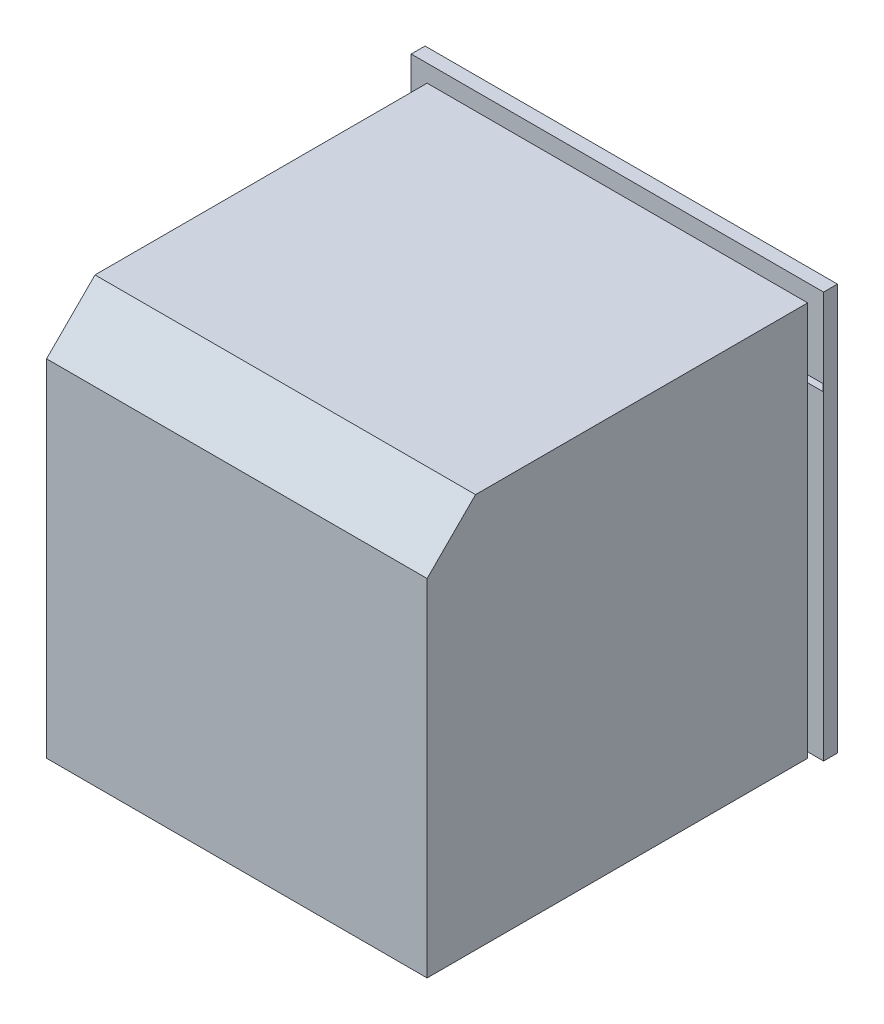
from build123d import *

# Parameters (mm, degrees)
SKETCH2_W           = 550
SKETCH2_H           = 570
BOSS_EXTRUDE2_DEPTH = 550
CHAMFER1_SIZE       = 70
SKETCH3_W           = 596
SKETCH3_H           = 595
BOSS_EXTRUDE3_DEPTH = 20
SKETCH4_W           = 595
SKETCH4_H           = 52
SKETCH4_W_2         = 596
SKETCH4_H_2         = 18
BOSS_EXTRUDE4_DEPTH = 0.01
SKETCH5_W           = 595
SKETCH5_H           = 8
SKETCH5_W_2         = 594
SKETCH5_H_2         = 10
CUT_EXTRUDE1_DEPTH  = 20.01
BOSS_EXTRUDE5_DEPTH = 30


with BuildPart() as part:
    # Sketch2 → Boss-Extrude2 (new body)
    with BuildSketch(Plane.XY):
        with Locations((0, 293.707988466)):
            Rectangle(SKETCH2_W, SKETCH2_H)
    extrude(amount=BOSS_EXTRUDE2_DEPTH)

    # Chamfer1
    chamfer1_edges = [part.edges().sort_by_distance(p)[0] for p in [
        (0, 578.707988466, 550),
    ]]
    chamfer(chamfer1_edges, length=CHAMFER1_SIZE)

    # Sketch3 → Boss-Extrude3 (add)
    with BuildSketch(Plane(origin=(0, 0, 0), x_dir=(-1, 0, 0), z_dir=(0, 0, -1))):
        with Locations((0, 306.207988466)):
            Rectangle(SKETCH3_W, SKETCH3_H)
    extrude(amount=BOSS_EXTRUDE3_DEPTH)

    # Sketch4 → Boss-Extrude4 (add)
    with BuildSketch(Plane(origin=(0, 0, -20), x_dir=(-1, 0, 0), z_dir=(0, 0, -1))):
        with Locations((-0.5, 34.707988466)):
            Rectangle(SKETCH4_W, SKETCH4_H)
        with Locations((0, 594.707988466)):
            Rectangle(SKETCH4_W_2, SKETCH4_H_2)
    extrude(amount=BOSS_EXTRUDE4_DEPTH)

    # Sketch5 → Cut-Extrude1 (cut)
    with BuildSketch(Plane(origin=(0, 0, -20.01), x_dir=(-1, 0, 0), z_dir=(0, 0, -1))):
        with Locations((-0.5, 12.707988466)):
            Rectangle(SKETCH5_W, SKETCH5_H)
        with Locations((0, 483.707988466)):
            Rectangle(SKETCH5_W_2, SKETCH5_H_2)
    extrude(amount=-CUT_EXTRUDE1_DEPTH, mode=Mode.SUBTRACT)


with BuildPart() as body_2:
    # Sketch7 → Boss-Extrude5 (new body)
    with BuildSketch(Plane(origin=(0, 468.707988466, 0), x_dir=(1, 0, 0), z_dir=(0, 1, 0))):
        Polygon((-209.116922129, 61.324222613), (220.883077871, 61.324222613), (220.883077871, 46.324222613), (220.883077871, 20.01), (200.883077871, 20.01), (200.883077871, 46.324222613), (-189.116922129, 46.324222613), (-189.116922129, 20.01), (-209.116922129, 20.01), (-209.116922129, 46.324222613), align=None)
    extrude(amount=-BOSS_EXTRUDE5_DEPTH)


solid = Compound([part.part, body_2.part])
